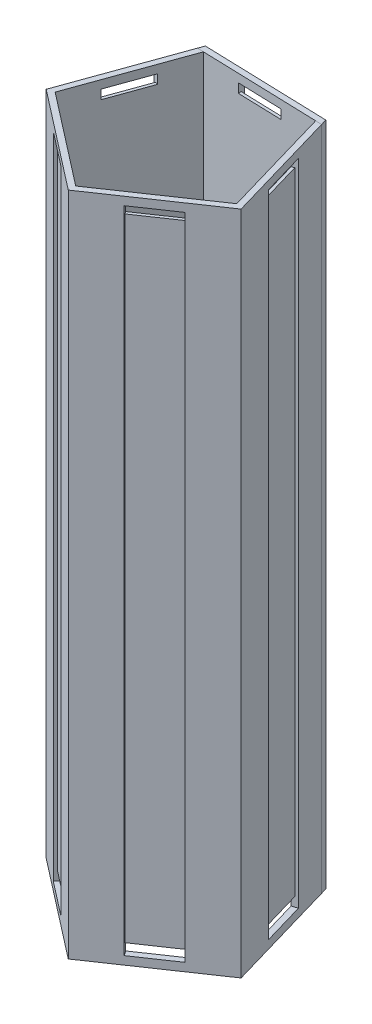
from build123d import *

# Parameters (mm, degrees)
BOSS_EXTRUDE2_DEPTH = 182
SKETCH3_W           = 12
SKETCH3_H           = 175
CUT_EXTRUDE1_DEPTH  = 0.8
SKETCH4_W           = 12
SKETCH4_H           = 2.5
CUT_EXTRUDE2_DEPTH  = 5
CIRPATTERN1_COUNT   = 5


with BuildPart() as part:
    # Sketch2 → Boss-Extrude2 (new body)
    with BuildSketch(Plane(origin=(0, 0, 0), x_dir=(1, 0, 0), z_dir=(0, 1, 0))):
        Polygon((17.724257502, 22.857119952), (-16.261316093, 23.920009101), (-27.774303549, -8.073741316), (-0.904147515, -28.909855651), (27.215509654, -9.793532086), align=None)
        Polygon((25.354620105, -9.123888867), (16.512342459, 21.294239955), (-15.149431232, 22.284452924), (-25.875205871, -7.521690627), (-0.842325462, -26.933113384), align=None, mode=Mode.SUBTRACT)
    extrude(amount=BOSS_EXTRUDE2_DEPTH)

    # Sketch3 → Cut-Extrude1 (cut)
    with BuildSketch(Plane(origin=(0.731470705, 0, -23.388564526), x_dir=(-0.999511304549409, 0, -0.03125943182367235), z_dir=(0.03125943182367234, 0, -0.9995113045494088))):
        with Locations((0, 91)):
            Rectangle(SKETCH3_W, SKETCH3_H)
    cut_extrude1 = extrude(amount=-CUT_EXTRUDE1_DEPTH, mode=Mode.SUBTRACT)

    # Sketch4 → Cut-Extrude2 (cut)
    with BuildSketch(Plane(origin=(0.731470705, 0, -23.388564526), x_dir=(-0.999511304549409, 0, -0.03125943182367227), z_dir=(0.031259431823672267, 0, -0.9995113045494088))):
        with Locations((0, 3.5)):
            Rectangle(SKETCH4_W, SKETCH4_H)
        with Locations((0, 178.5)):
            Rectangle(SKETCH4_W, SKETCH4_H)
    cut_extrude2 = extrude(amount=-CUT_EXTRUDE2_DEPTH, mode=Mode.SUBTRACT)

    # CirPattern1: Cut-Extrude1, Cut-Extrude2 ×5 about axis
    cirpattern1_axis = Axis((0, 0, 0), (0, 1, 0))
    add([cut_extrude1.rotate(cirpattern1_axis, i * 360 / CIRPATTERN1_COUNT) for i in range(1, CIRPATTERN1_COUNT)], mode=Mode.SUBTRACT)
    add([cut_extrude2.rotate(cirpattern1_axis, i * 360 / CIRPATTERN1_COUNT) for i in range(1, CIRPATTERN1_COUNT)], mode=Mode.SUBTRACT)


with BuildPart() as body_2:
    # Split1: the piece on the far side of the plane
    add(part.part)
    split(bisect_by=Plane(origin=(0.681455614, 0, -21.789346439), x_dir=(0.999511304549409, 0, 0.03125943182367256), z_dir=(-0.03125943182367256, 0, 0.999511304549409)), keep=Keep.BOTTOM)


with BuildPart() as part_1:
    add(part.part)

    # Split1
    split(bisect_by=Plane(origin=(0.681455614, 0, -21.789346439), x_dir=(0.999511304549409, 0, 0.03125943182367256), z_dir=(-0.03125943182367256, 0, 0.999511304549409)), keep=Keep.TOP)


solid = Compound([body_2.part, part_1.part])
